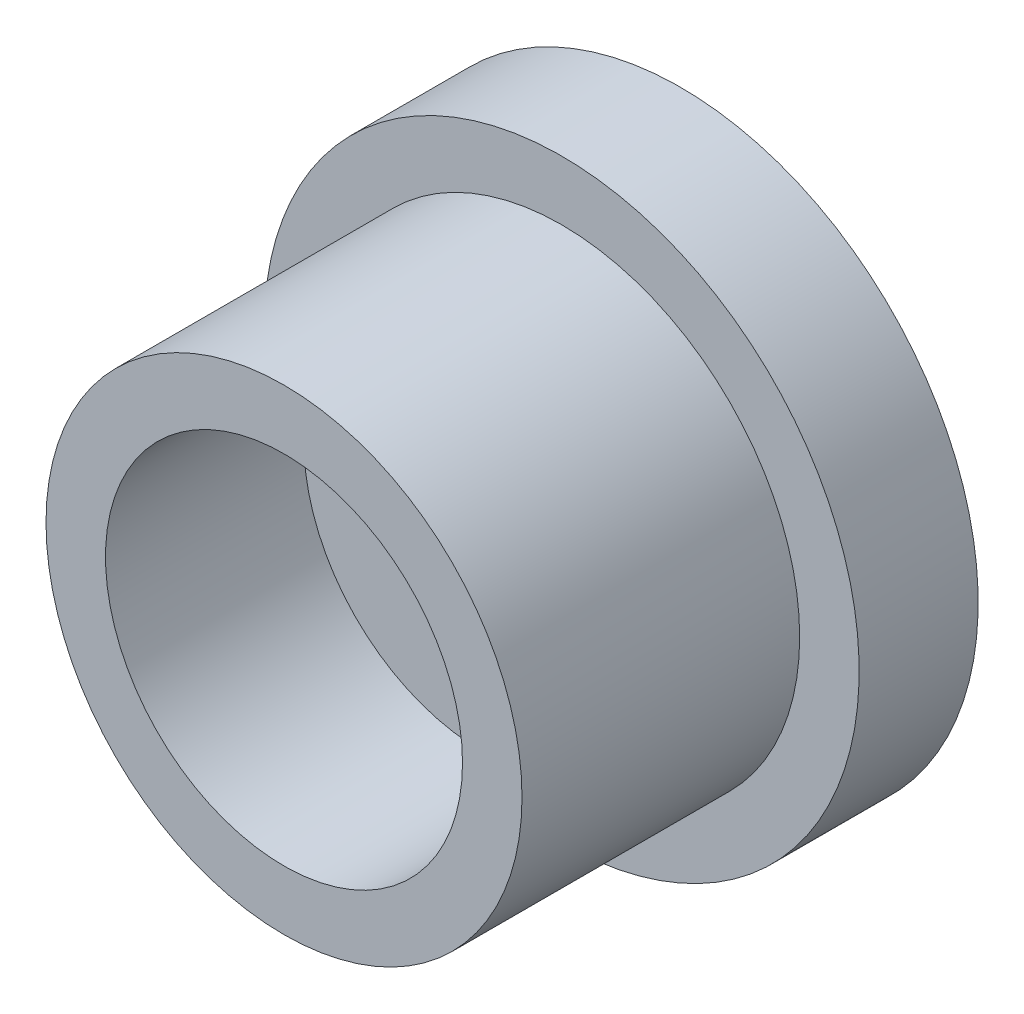
from build123d import *

# Parameters (mm, degrees)
SCHIZZO1_R                   = 6
ESTRUSIONE_ESTRUSIONE1_DEPTH = 7
SCHIZZO2_R                   = 4.5
TAGLIO_ESTRUSIONE1_DEPTH     = 5
SCHIZZO3_R                   = 7.5
ESTRUSIONE_ESTRUSIONE2_DEPTH = 3


with BuildPart() as part:
    # Schizzo1 → Estrusione-Estrusione1 (new body)
    with BuildSketch(Plane.XY):
        Circle(SCHIZZO1_R)
    extrude(amount=ESTRUSIONE_ESTRUSIONE1_DEPTH)

    # Schizzo2 → Taglio-Estrusione1 (cut)
    with BuildSketch(Plane.XY.offset(7)):
        Circle(SCHIZZO2_R)
    extrude(amount=-TAGLIO_ESTRUSIONE1_DEPTH, mode=Mode.SUBTRACT)

    # Schizzo3 → Estrusione-Estrusione2 (add)
    with BuildSketch(Plane(origin=(0, 0, 0), x_dir=(-1, 0, 0), z_dir=(0, 0, -1))):
        Circle(SCHIZZO3_R)
    extrude(amount=ESTRUSIONE_ESTRUSIONE2_DEPTH)


solid = part.part
